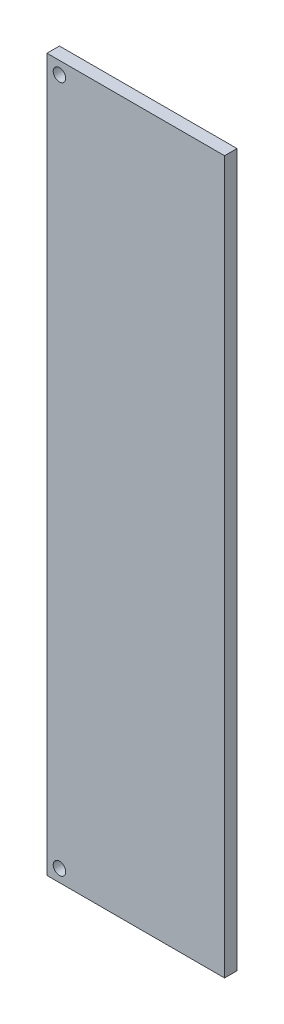
from build123d import *

# Parameters (mm, degrees)
SKETCH1_W           = 28.5
SKETCH1_H           = 114.3
BOSS_EXTRUDE1_DEPTH = 2
SKETCH2_R           = 1
CUT_EXTRUDE1_DEPTH  = 3


with BuildPart() as part:
    # Sketch1 → Boss-Extrude1 (new body)
    with BuildSketch(Plane.XY):
        with Locations((-78.123529412, 6.723529412)):
            Rectangle(SKETCH1_W, SKETCH1_H)
    extrude(amount=BOSS_EXTRUDE1_DEPTH)

    # Sketch2 → Cut-Extrude1 (cut, through all)
    with BuildSketch(Plane.XY.offset(2)):
        with Locations((-90.373529412, 61.873529412)):
            Circle(SKETCH2_R)
        with Locations((-90.373529412, -48.426470588)):
            Circle(SKETCH2_R)
    extrude(amount=-CUT_EXTRUDE1_DEPTH, mode=Mode.SUBTRACT)


solid = part.part
